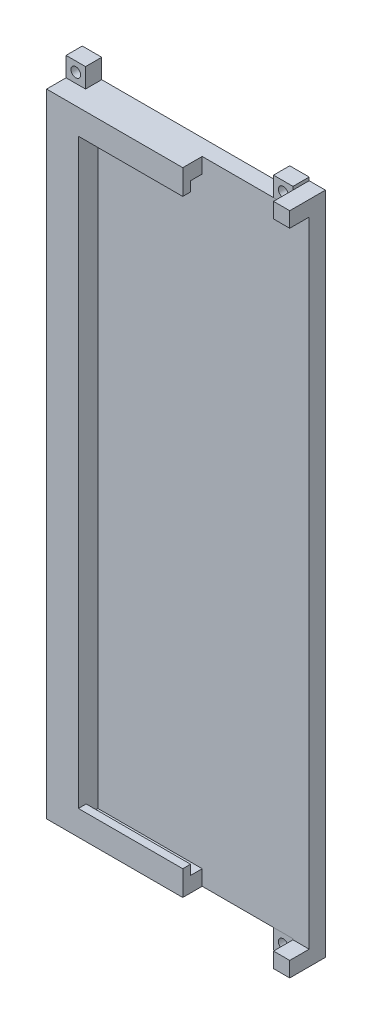
from build123d import *

# Parameters (mm, degrees)
BOSS_EXTRUDE1_DEPTH   = 5
SKETCH4_W             = 5
SKETCH4_H             = 4.7
BOSS_EXTRUDE2_DEPTH   = 6
SKETCH5_W             = 3
SKETCH5_H             = 2.4
BOSS_EXTRUDE3_DEPTH   = 32.2
SKETCH6_W             = 6
SKETCH6_H             = 6
BOSS_EXTRUDE4_DEPTH   = 5
BOSS_EXTRUDE4_2_DEPTH = 5
BOSS_EXTRUDE4_3_DEPTH = 5
BOSS_EXTRUDE4_4_DEPTH = 5
SKETCH7_R             = 1.5
CUT_EXTRUDE1_DEPTH    = 6


with BuildPart() as part:
    # Sketch1 → Boss-Extrude1 (new body)
    with BuildSketch(Plane(origin=(0, 0, 0), x_dir=(0, 1, 0), z_dir=(0, 0, 1))):
        Polygon((-97.5, 5), (-97.5, 75), (97.5, 75), (97.5, 5), (102.5, 5), (102.5, 0), (-102.5, 0), (-102.5, 5), align=None)
    extrude(amount=BOSS_EXTRUDE1_DEPTH)

    # Sketch4 → Boss-Extrude2 (add)
    with BuildSketch(Plane.XY.offset(5)):
        Polygon((-75, 97.5), (-75, -97.5), (-33, -97.5), (-33, -92.8), (-65.2, -92.8), (-65.2, 92.8), (-33, 92.8), (-33, 97.5), align=None)
        with Locations((-2.5, 100.15)):
            Rectangle(SKETCH4_W, SKETCH4_H)
        with Locations((-2.5, -100.15)):
            Rectangle(SKETCH4_W, SKETCH4_H)
    extrude(amount=BOSS_EXTRUDE2_DEPTH)

    # Sketch5 → Boss-Extrude3 (add)
    with BuildSketch(Plane.YZ.offset(-65.2)):
        with Locations((-91.3, 9.8)):
            Rectangle(SKETCH5_W, SKETCH5_H)
        with Locations((91.3, 9.8)):
            Rectangle(SKETCH5_W, SKETCH5_H)
    extrude(amount=BOSS_EXTRUDE3_DEPTH)


with BuildPart() as body_2:
    # Sketch6 → Boss-Extrude4 (new body)
    with BuildSketch(Plane(origin=(0, 0, 0), x_dir=(1, 0, 0), z_dir=(0, 0, -1))):
        with Locations((-8, 100.5)):
            Rectangle(SKETCH6_W, SKETCH6_H)
    extrude(amount=-BOSS_EXTRUDE4_DEPTH)


with BuildPart() as body_3:
    # Sketch6 → Boss-Extrude4 2 (new body)
    with BuildSketch(Plane(origin=(0, 0, 0), x_dir=(1, 0, 0), z_dir=(0, 0, -1))):
        with Locations((-72, 100.5)):
            Rectangle(SKETCH6_W, SKETCH6_H)
    extrude(amount=-BOSS_EXTRUDE4_2_DEPTH)


with BuildPart() as body_4:
    # Sketch6 → Boss-Extrude4 3 (new body)
    with BuildSketch(Plane(origin=(0, 0, 0), x_dir=(1, 0, 0), z_dir=(0, 0, -1))):
        with Locations((-8, -100.5)):
            Rectangle(SKETCH6_W, SKETCH6_H)
    extrude(amount=-BOSS_EXTRUDE4_3_DEPTH)


with BuildPart() as body_5:
    # Sketch6 → Boss-Extrude4 4 (new body)
    with BuildSketch(Plane(origin=(0, 0, 0), x_dir=(1, 0, 0), z_dir=(0, 0, -1))):
        with Locations((-72, -100.5)):
            Rectangle(SKETCH6_W, SKETCH6_H)
    extrude(amount=-BOSS_EXTRUDE4_4_DEPTH)


with BuildPart() as cut_extrude1_tool:
    # Sketch7 → Cut-Extrude1 (new body, through all)
    with BuildSketch(Plane.XY.offset(5)):
        with Locations((-8, -100.5)):
            Circle(SKETCH7_R)
        with Locations((-72, -100.5)):
            Circle(SKETCH7_R)
        with Locations((-8, 100.5)):
            Circle(SKETCH7_R)
        with Locations((-72, 100.5)):
            Circle(SKETCH7_R)
    extrude(amount=-CUT_EXTRUDE1_DEPTH)


with BuildPart() as body_2_1:
    add(body_2.part)

    # Cut-Extrude1: cut by cut_extrude1_tool
    add(cut_extrude1_tool.part, mode=Mode.SUBTRACT)


with BuildPart() as body_3_1:
    add(body_3.part)

    # Cut-Extrude1: cut by cut_extrude1_tool
    add(cut_extrude1_tool.part, mode=Mode.SUBTRACT)


with BuildPart() as body_4_1:
    add(body_4.part)

    # Cut-Extrude1: cut by cut_extrude1_tool
    add(cut_extrude1_tool.part, mode=Mode.SUBTRACT)


with BuildPart() as body_5_1:
    add(body_5.part)

    # Cut-Extrude1: cut by cut_extrude1_tool
    add(cut_extrude1_tool.part, mode=Mode.SUBTRACT)


solid = Compound([part.part, body_2_1.part, body_3_1.part, body_4_1.part, body_5_1.part])
